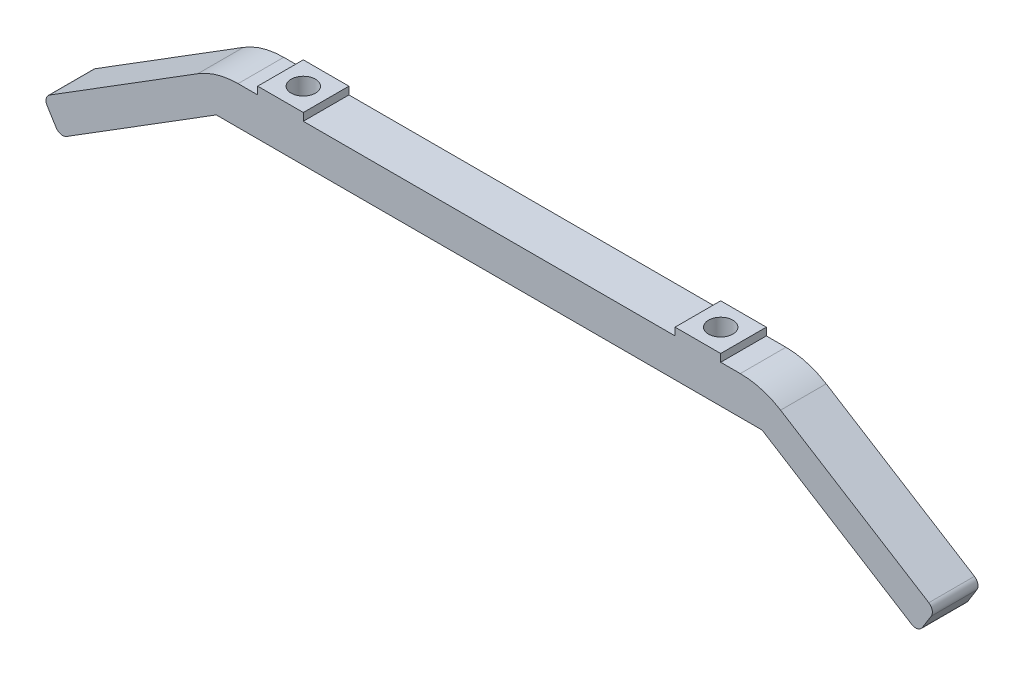
from build123d import *

# Parameters (mm, degrees)
EXTRUDE_1_DEPTH      = 3
SKETCH_7_R           = 2.25
CUT_EXTRUDE_2_DEPTH  = 4.0000001
SKETCH_8_R           = 8
CUT_EXTRUDE_3_DEPTH  = 4.0000001
CUT_EXTRUDE_4_DEPTH  = 3
CUT_EXTRUDE_5_DEPTH  = 3
CUT_EXTRUDE_8_DEPTH  = 3
SKETCH_12_R          = 1.7
CUT_EXTRUDE_9_DEPTH  = 3
SKETCH_13_R          = 1.7
CUT_EXTRUDE_11_DEPTH = 3
CUT_EXTRUDE_12_DEPTH = 4.0000001
FILLET_1_R           = 2
FILLET_2_R           = 2
CUT_EXTRUDE_13_DEPTH = 4.0000001
CUT_EXTRUDE_14_DEPTH = 4.0000001
CUT_EXTRUDE_15_DEPTH = 4.0000001
CUT_EXTRUDE_16_DEPTH = 4.0000001
SKETCH_19_W          = 174.604309186
SKETCH_19_H          = 153.794857067
CUT_EXTRUDE_17_DEPTH = 10
SKETCH_20_R          = 1.7
SKETCH_20_R_2        = 2.929115441
EXTRUDE_2_DEPTH      = 5
SKETCH_21_W          = 71.778327268
SKETCH_21_H          = 4.999657954
EXTRUDE_3_DEPTH      = 5
EXTRUDE_4_DEPTH      = 5
FILLET_3_R           = 10
SKETCH_23_W          = 71.778327268
SKETCH_23_H          = 4.999657954
EXTRUDE_5_DEPTH      = 5
FILLET_4_R           = 1
SKETCH_24_W          = 6
SKETCH_24_H          = 4.999657954
EXTRUDE_7_DEPTH      = 55
EXTRUDE_8_DEPTH      = 4.999658
FILLET_5_R           = 8
FILLET_6_R           = 12
SKETCH_27_W          = 5
SKETCH_27_H          = 6
EXTRUDE_9_DEPTH      = 4.999658
FILLET_7_R           = 1
FILLET_8_R           = 1
FILLET_9_R           = 1
SKETCH_28_R          = 1.6
CUT_EXTRUDE_19_DEPTH = 50
EXTRUDE_10_DEPTH     = 6
SKETCH_33_R          = 1.6
CUT_EXTRUDE_21_DEPTH = 10.999657954
SKETCH_34_W          = 162.843072653
SKETCH_34_H          = 93.113374014
CUT_EXTRUDE_22_DEPTH = 10
SKETCH_35_W          = 6
SKETCH_35_H          = 6
SKETCH_35_R          = 1.6
EXTRUDE_11_DEPTH     = 1
CUT_EXTRUDE_23_DEPTH = 90
SKETCH_37_W          = 26
SKETCH_37_H          = 5
CUT_EXTRUDE_24_DEPTH = 90
FILLET_10_R          = 10
FILLET_11_R          = 1


with BuildPart() as part:
    # 草图1 → 凸台-拉伸1 (new body)
    with BuildSketch(Plane.XY):
        with BuildLine():
            Line((60, 106.603296002), (35.889163634, 121.664519159))
            Line((35.889163634, 121.664519159), (-35.889163634, 121.664519159))
            Line((-35.889163634, 121.664519159), (-60, 106.603296002))
            Line((-60, 106.603296002), (-60, 94.801892265))
            Line((-60, 94.801892265), (-45, 94.801892265))
            ThreePointArc((-45, 94.801892265), (-43.762563133, 94.289329132), (-43.25, 93.051892265))
            Line((-43.25, 93.051892265), (-37.75, 93.051892265))
            ThreePointArc((-37.75, 93.051892265), (-37.237436867, 94.289329132), (-36, 94.801892265))
            Line((-36, 94.801892265), (-21, 94.801892265))
            ThreePointArc((-21, 94.801892265), (-19.762563133, 94.289329132), (-19.25, 93.051892265))
            Line((-19.25, 93.051892265), (19.25, 93.051892265))
            ThreePointArc((19.25, 93.051892265), (19.762563133, 94.289329132), (21, 94.801892265))
            Line((21, 94.801892265), (36, 94.801892265))
            ThreePointArc((36, 94.801892265), (37.237436867, 94.289329132), (37.75, 93.051892265))
            Line((37.75, 93.051892265), (43.25, 93.051892265))
            ThreePointArc((43.25, 93.051892265), (43.762563133, 94.289329132), (45, 94.801892265))
            Line((45, 94.801892265), (60, 94.801892265))
            Line((60, 94.801892265), (60, 106.603296002))
        make_face()
        with BuildLine():
            Line((66.901694095, 102.292041372), (60, 106.603296002))
            Line((60, 106.603296002), (60, 94.801892265))
            ThreePointArc((60, 94.801892265), (61.237436867, 94.289329132), (61.75, 93.051892265))
            Line((61.75, 93.051892265), (66.901694095, 93.051892265))
            Line((66.901694095, 93.051892265), (66.901694095, 102.292041372))
        make_face()
        with BuildLine():
            Line((-60, 94.801892265), (-60, 106.603296002))
            Line((-60, 106.603296002), (-66.901694095, 102.292041372))
            Line((-66.901694095, 102.292041372), (-66.901694095, 93.051892265))
            Line((-66.901694095, 93.051892265), (-61.75, 93.051892265))
            ThreePointArc((-61.75, 93.051892265), (-61.237436867, 94.289329132), (-60, 94.801892265))
        make_face()
        with BuildLine():
            Line((66.901694095, 63.051892265), (66.901694095, 93.051892265))
            Line((66.901694095, 93.051892265), (61.75, 93.051892265))
            ThreePointArc((61.75, 93.051892265), (61.237436867, 91.814455398), (60, 91.301892265))
            Line((60, 91.301892265), (60, 64.801892265))
            ThreePointArc((60, 64.801892265), (61.237436867, 64.289329132), (61.75, 63.051892265))
            Line((61.75, 63.051892265), (66.901694095, 63.051892265))
        make_face()
        with BuildLine():
            Line((-61.75, 93.051892265), (-66.901694095, 93.051892265))
            Line((-66.901694095, 93.051892265), (-66.901694095, 63.051892265))
            Line((-66.901694095, 63.051892265), (-61.75, 63.051892265))
            ThreePointArc((-61.75, 63.051892265), (-61.237436867, 64.289329132), (-60, 64.801892265))
            Line((-60, 64.801892265), (-60, 91.301892265))
            ThreePointArc((-60, 91.301892265), (-61.237436867, 91.814455398), (-61.75, 93.051892265))
        make_face()
        with BuildLine():
            Line((66.901694095, 52.870133869), (66.901694095, 63.051892265))
            Line((66.901694095, 63.051892265), (61.75, 63.051892265))
            ThreePointArc((61.75, 63.051892265), (61.237436867, 61.814455398), (60, 61.301892265))
            Line((60, 61.301892265), (60, 31.261343001))
            Line((60, 31.261343001), (75, 31.261343001))
            Line((75, 31.261343001), (75, 40.933889795))
            ThreePointArc((75, 40.933889795), (69.117351927, 45.658052319), (66.901694095, 52.870133869))
        make_face()
        with BuildLine():
            Line((60, 64.801892265), (60, 91.301892265))
            Line((60, 91.301892265), (45, 91.301892265))
            ThreePointArc((45, 91.301892265), (43.762563133, 91.814455398), (43.25, 93.051892265))
            Line((43.25, 93.051892265), (37.75, 93.051892265))
            ThreePointArc((37.75, 93.051892265), (37.237436867, 91.814455398), (36, 91.301892265))
            Line((36, 91.301892265), (21, 91.301892265))
            ThreePointArc((21, 91.301892265), (19.762563133, 91.814455398), (19.25, 93.051892265))
            Line((19.25, 93.051892265), (-19.25, 93.051892265))
            ThreePointArc((-19.25, 93.051892265), (-19.762563133, 91.814455398), (-21, 91.301892265))
            Line((-21, 91.301892265), (-36, 91.301892265))
            ThreePointArc((-36, 91.301892265), (-37.237436867, 91.814455398), (-37.75, 93.051892265))
            Line((-37.75, 93.051892265), (-43.25, 93.051892265))
            ThreePointArc((-43.25, 93.051892265), (-43.762563133, 91.814455398), (-45, 91.301892265))
            Line((-45, 91.301892265), (-60, 91.301892265))
            Line((-60, 91.301892265), (-60, 64.801892265))
            Line((-60, 64.801892265), (-45, 64.801892265))
            ThreePointArc((-45, 64.801892265), (-43.762563133, 64.289329132), (-43.25, 63.051892265))
            Line((-43.25, 63.051892265), (-37.75, 63.051892265))
            ThreePointArc((-37.75, 63.051892265), (-37.237436867, 64.289329132), (-36, 64.801892265))
            Line((-36, 64.801892265), (-21, 64.801892265))
            ThreePointArc((-21, 64.801892265), (-19.762563133, 64.289329132), (-19.25, 63.051892265))
            Line((-19.25, 63.051892265), (19.25, 63.051892265))
            ThreePointArc((19.25, 63.051892265), (19.762563133, 64.289329132), (21, 64.801892265))
            Line((21, 64.801892265), (36, 64.801892265))
            ThreePointArc((36, 64.801892265), (37.237436867, 64.289329132), (37.75, 63.051892265))
            Line((37.75, 63.051892265), (43.25, 63.051892265))
            ThreePointArc((43.25, 63.051892265), (43.762563133, 64.289329132), (45, 64.801892265))
            Line((45, 64.801892265), (60, 64.801892265))
        make_face()
        with BuildLine():
            Line((-61.75, 63.051892265), (-66.901694095, 63.051892265))
            Line((-66.901694095, 63.051892265), (-66.901694095, 52.870133869))
            ThreePointArc((-66.901694095, 52.870133869), (-69.117351927, 45.658052319), (-75, 40.933889795))
            Line((-75, 40.933889795), (-75, 31.261343001))
            Line((-75, 31.261343001), (-60, 31.261343001))
            Line((-60, 31.261343001), (-60, 61.301892265))
            ThreePointArc((-60, 61.301892265), (-61.237436867, 61.814455398), (-61.75, 63.051892265))
        make_face()
        with BuildLine():
            Line((60, 31.261343001), (60, 61.301892265))
            Line((60, 61.301892265), (45, 61.301892265))
            ThreePointArc((45, 61.301892265), (43.762563133, 61.814455398), (43.25, 63.051892265))
            Line((43.25, 63.051892265), (37.75, 63.051892265))
            ThreePointArc((37.75, 63.051892265), (37.237436867, 61.814455398), (36, 61.301892265))
            Line((36, 61.301892265), (21, 61.301892265))
            ThreePointArc((21, 61.301892265), (19.762563133, 61.814455398), (19.25, 63.051892265))
            Line((19.25, 63.051892265), (-19.25, 63.051892265))
            ThreePointArc((-19.25, 63.051892265), (-19.762563133, 61.814455398), (-21, 61.301892265))
            Line((-21, 61.301892265), (-36, 61.301892265))
            ThreePointArc((-36, 61.301892265), (-37.237436867, 61.814455398), (-37.75, 63.051892265))
            Line((-37.75, 63.051892265), (-43.25, 63.051892265))
            ThreePointArc((-43.25, 63.051892265), (-43.762563133, 61.814455398), (-45, 61.301892265))
            Line((-45, 61.301892265), (-60, 61.301892265))
            Line((-60, 61.301892265), (-60, 31.261343001))
            Line((-60, 31.261343001), (60, 31.261343001))
        make_face()
        with BuildLine():
            Line((60, -58.312864289), (60, 23.940028391))
            Line((60, 23.940028391), (-60, 23.940028391))
            Line((-60, 23.940028391), (-60, -58.312864289))
            Line((-60, -58.312864289), (-45, -58.312864289))
            ThreePointArc((-45, -58.312864289), (-43.25, -60.062864289), (-45, -61.812864289))
            Line((-45, -61.812864289), (-60, -61.812864289))
            Line((-60, -61.812864289), (-60, -88.312864289))
            Line((-60, -88.312864289), (-45, -88.312864289))
            ThreePointArc((-45, -88.312864289), (-43.25, -90.062864289), (-45, -91.812864289))
            Line((-45, -91.812864289), (-60, -91.812864289))
            Line((-60, -91.812864289), (-60, -111.849967256))
            Line((-60, -111.849967256), (-38.845469114, -105.590576733))
            ThreePointArc((-38.845469114, -105.590576733), (-36.037784492, -104.975210108), (-33.17088573, -104.768665882))
            Line((-33.17088573, -104.768665882), (33.17088573, -104.768665882))
            ThreePointArc((33.17088573, -104.768665882), (36.037784492, -104.975210108), (38.845469114, -105.590576733))
            Line((38.845469114, -105.590576733), (60, -111.849967256))
            Line((60, -111.849967256), (60, -91.812864289))
            Line((60, -91.812864289), (45, -91.812864289))
            ThreePointArc((45, -91.812864289), (43.762563133, -91.300301156), (43.25, -90.062864289))
            ThreePointArc((43.25, -90.062864289), (43.762563133, -88.825427422), (45, -88.312864289))
            Line((45, -88.312864289), (60, -88.312864289))
            Line((60, -88.312864289), (60, -61.812864289))
            Line((60, -61.812864289), (45, -61.812864289))
            ThreePointArc((45, -61.812864289), (43.762563133, -61.300301156), (43.25, -60.062864289))
            ThreePointArc((43.25, -60.062864289), (43.762563133, -58.825427422), (45, -58.312864289))
            Line((45, -58.312864289), (60, -58.312864289))
        make_face()
        with BuildLine():
            ThreePointArc((-21, -88.312864289), (-19.762563133, -88.825427422), (-19.25, -90.062864289))
            ThreePointArc((-19.25, -90.062864289), (-19.762563133, -91.300301156), (-21, -91.812864289))
            Line((-21, -91.812864289), (-36, -91.812864289))
            ThreePointArc((-36, -91.812864289), (-37.75, -90.062864289), (-36, -88.312864289))
            Line((-36, -88.312864289), (-21, -88.312864289))
        make_face(mode=Mode.SUBTRACT)
        with BuildLine():
            ThreePointArc((-21, -58.312864289), (-19.762563133, -58.825427422), (-19.25, -60.062864289))
            ThreePointArc((-19.25, -60.062864289), (-19.762563133, -61.300301156), (-21, -61.812864289))
            Line((-21, -61.812864289), (-36, -61.812864289))
            ThreePointArc((-36, -61.812864289), (-37.75, -60.062864289), (-36, -58.312864289))
            Line((-36, -58.312864289), (-21, -58.312864289))
        make_face(mode=Mode.SUBTRACT)
        with BuildLine():
            ThreePointArc((36, -88.312864289), (37.237436867, -88.825427422), (37.75, -90.062864289))
            ThreePointArc((37.75, -90.062864289), (37.237436867, -91.300301156), (36, -91.812864289))
            Line((36, -91.812864289), (21, -91.812864289))
            ThreePointArc((21, -91.812864289), (19.762563133, -91.300301156), (19.25, -90.062864289))
            ThreePointArc((19.25, -90.062864289), (19.762563133, -88.825427422), (21, -88.312864289))
            Line((21, -88.312864289), (36, -88.312864289))
        make_face(mode=Mode.SUBTRACT)
        with BuildLine():
            ThreePointArc((36, -58.312864289), (37.237436867, -58.825427422), (37.75, -60.062864289))
            ThreePointArc((37.75, -60.062864289), (37.237436867, -61.300301156), (36, -61.812864289))
            Line((36, -61.812864289), (21, -61.812864289))
            ThreePointArc((21, -61.812864289), (19.762563133, -61.300301156), (19.25, -60.062864289))
            ThreePointArc((19.25, -60.062864289), (19.762563133, -58.825427422), (21, -58.312864289))
            Line((21, -58.312864289), (36, -58.312864289))
        make_face(mode=Mode.SUBTRACT)
        with BuildLine():
            Line((75, 23.940028391), (60, 23.940028391))
            Line((60, 23.940028391), (60, -58.312864289))
            ThreePointArc((60, -58.312864289), (61.237436867, -58.825427422), (61.75, -60.062864289))
            Line((61.75, -60.062864289), (67.402721334, -60.062864289))
            add(Edge.make_bspline(
                [(75, 10.562559835), (72.695878257, 1.907314233), (70.339582535, -13.372796253), (67.818206704, -36.939032951), (67.208860388, -51.77269444), (67.402721334, -60.062864289)],
                knots=[0, 0, 0, 0, 0.235246678, 0.40629419, 0.624108181, 0.624108181, 0.624108181, 0.624108181], degree=3))
            Line((75, 10.562559835), (75, 23.940028391))
        make_face()
        with BuildLine():
            Line((-60, -58.312864289), (-60, 23.940028391))
            Line((-60, 23.940028391), (-75, 23.940028391))
            Line((-75, 23.940028391), (-75, 10.562559835))
            add(Edge.make_bspline(
                [(-75, 10.562559835), (-72.695878257, 1.907314233), (-70.339582535, -13.372796253), (-67.818206704, -36.939032951), (-67.208860388, -51.77269444), (-67.402721334, -60.062864289)],
                knots=[0, 0, 0, 0, 0.235246678, 0.40629419, 0.624108181, 0.624108181, 0.624108181, 0.624108181], degree=3))
            add(Edge.make_bspline(
                [(-67.402721334, -60.062864289), (-67.560325872, -66.802583754), (-68.323504015, -76.843670093), (-70.154131955, -86.778530076), (-70.533712858, -90.062864289)],
                knots=[0.624108181, 0.624108181, 0.624108181, 0.624108181, 0.801186001, 0.888408652, 0.888408652, 0.888408652, 0.888408652], degree=3))
            add(Edge.make_bspline(
                [(-70.533712858, -90.062864289), (-71.019342956, -94.264792095), (-71.137422935, -98.476048206), (-70.1742624, -102.732794059)],
                knots=[0.888408652, 0.888408652, 0.888408652, 0.888408652, 1, 1, 1, 1], degree=3))
            Line((-70.1742624, -102.732794059), (-66.460817635, -113.761651372))
            Line((-66.460817635, -113.761651372), (-60, -111.849967256))
            Line((-60, -111.849967256), (-60, -91.812864289))
            ThreePointArc((-60, -91.812864289), (-61.75, -90.062864289), (-60, -88.312864289))
            Line((-60, -88.312864289), (-60, -61.812864289))
            ThreePointArc((-60, -61.812864289), (-61.75, -60.062864289), (-60, -58.312864289))
        make_face()
        with BuildLine():
            Line((67.402721334, -60.062864289), (61.75, -60.062864289))
            ThreePointArc((61.75, -60.062864289), (61.237436867, -61.300301156), (60, -61.812864289))
            Line((60, -61.812864289), (60, -88.312864289))
            ThreePointArc((60, -88.312864289), (61.237436867, -88.825427422), (61.75, -90.062864289))
            Line((61.75, -90.062864289), (70.533712858, -90.062864289))
            add(Edge.make_bspline(
                [(67.402721334, -60.062864289), (67.560325872, -66.802583754), (68.323504015, -76.843670093), (70.154131955, -86.778530076), (70.533712858, -90.062864289)],
                knots=[0.624108181, 0.624108181, 0.624108181, 0.624108181, 0.801186001, 0.888408652, 0.888408652, 0.888408652, 0.888408652], degree=3))
        make_face()
        with BuildLine():
            add(Edge.make_bspline(
                [(70.533712858, -90.062864289), (71.019342956, -94.264792095), (71.137422935, -98.476048206), (70.1742624, -102.732794059)],
                knots=[0.888408652, 0.888408652, 0.888408652, 0.888408652, 1, 1, 1, 1], degree=3))
            Line((70.533712858, -90.062864289), (61.75, -90.062864289))
            ThreePointArc((61.75, -90.062864289), (61.237436867, -91.300301156), (60, -91.812864289))
            Line((60, -91.812864289), (60, -111.849967256))
            Line((60, -111.849967256), (66.460817635, -113.761651372))
            Line((66.460817635, -113.761651372), (70.1742624, -102.732794059))
        make_face()
    extrude(amount=EXTRUDE_1_DEPTH)

    # 草图7 → 切除-拉伸2 (cut, through all)
    with BuildSketch(Plane(origin=(0, 0, 0), x_dir=(-1, 0, 0), z_dir=(0, 0, -1))):
        with Locations((-21, 41.261343001)):
            Circle(SKETCH_7_R)
        with Locations((21, 41.261343001)):
            Circle(SKETCH_7_R)
        with Locations((-21, 13.940028391)):
            Circle(SKETCH_7_R)
        with Locations((21, 13.940028391)):
            Circle(SKETCH_7_R)
    extrude(amount=-CUT_EXTRUDE_2_DEPTH, mode=Mode.SUBTRACT)

    # 草图8 → 切除-拉伸3 (cut, through all)
    with BuildSketch(Plane.XY.offset(3)):
        with BuildLine():
            Line((-12.621438714, -0.378557945), (-33.409010345, 20.409013685))
            ThreePointArc((-33.409010345, 20.409013685), (-36.590999434, 20.409013643), (-36.590999309, 17.227024553))
            Line((-36.590999309, 17.227024553), (-15.803426586, -3.560545984))
            ThreePointArc((-15.803426586, -3.560545984), (-12.621438673, -3.560545859), (-12.621438714, -0.378557945))
        make_face()
        with BuildLine():
            Line((33.410462056, 20.410458798), (12.572988319, -0.427010824))
            ThreePointArc((12.572988319, -0.427010824), (12.644570441, -3.584764993), (15.803045702, -3.56090242))
            Line((15.803045702, -3.56090242), (34.999999982, 15.636052774))
            Line((34.999999982, 15.636052774), (36.588086952, 17.224139819))
            ThreePointArc((36.588086952, 17.224139819), (36.592433993, 20.406111757), (33.410462056, 20.410458798))
        make_face()
        with BuildLine():
            Line((-15.803784812, -28.80377835), (-36.591002186, -49.590991619))
            ThreePointArc((-36.591002186, -49.590991619), (-36.591002403, -52.772972232), (-33.40902179, -52.772972254))
            Line((-33.40902179, -52.772972254), (-12.573723916, -31.937673388))
            ThreePointArc((-12.573723916, -31.937673388), (-12.64530628, -28.779915954), (-15.803784812, -28.80377835))
        make_face()
        with BuildLine():
            Line((36.590992666, -49.590989326), (15.803414627, -28.803411286))
            ThreePointArc((15.803414627, -28.803411286), (12.654338964, -28.769774302), (12.55344336, -31.917412949))
            Line((12.55344336, -31.917412949), (33.409007381, -52.772974779))
            ThreePointArc((33.409007381, -52.772974779), (36.590992708, -52.772974653), (36.590992666, -49.590989326))
        make_face()
        with Locations((-0.000368782, -16.182341354)):
            Circle(SKETCH_8_R)
    extrude(amount=-CUT_EXTRUDE_3_DEPTH, mode=Mode.SUBTRACT)

    # 草图9 → 切除-拉伸4 (cut)
    with BuildSketch(Plane.XY.offset(3)):
        with BuildLine():
            Line((55, -100.49704609), (20, -100.49704609))
            ThreePointArc((20, -100.49704609), (18.25, -98.74704609), (20, -96.99704609))
            Line((20, -96.99704609), (55, -96.99704609))
            ThreePointArc((55, -96.99704609), (56.75, -98.74704609), (55, -100.49704609))
        make_face()
        with BuildLine():
            Line((-55, -96.99704609), (-20, -96.99704609))
            ThreePointArc((-20, -96.99704609), (-18.25, -98.74704609), (-20, -100.49704609))
            Line((-20, -100.49704609), (-55, -100.49704609))
            ThreePointArc((-55, -100.49704609), (-56.75, -98.74704609), (-55, -96.99704609))
        make_face()
    extrude(amount=-CUT_EXTRUDE_4_DEPTH, mode=Mode.SUBTRACT)

    # 草图10 → 切除-拉伸5 (cut)
    with BuildSketch(Plane.XY.offset(3)):
        with BuildLine():
            Line((12.5, -80.062864289), (-12.5, -80.062864289))
            ThreePointArc((-12.5, -80.062864289), (-17.5, -75.062864289), (-12.5, -70.062864289))
            Line((-12.5, -70.062864289), (12.5, -70.062864289))
            ThreePointArc((12.5, -70.062864289), (17.5, -75.062864289), (12.5, -80.062864289))
        make_face()
    extrude(amount=-CUT_EXTRUDE_5_DEPTH, mode=Mode.SUBTRACT)

    # 草图11 → 切除-拉伸8 (cut)
    with BuildSketch(Plane.XY.offset(3)):
        with BuildLine():
            Line((15, 73.051892265), (-15, 73.051892265))
            ThreePointArc((-15, 73.051892265), (-20, 78.051892265), (-15, 83.051892265))
            Line((-15, 83.051892265), (15, 83.051892265))
            ThreePointArc((15, 83.051892265), (20, 78.051892265), (15, 73.051892265))
        make_face()
    extrude(amount=-CUT_EXTRUDE_8_DEPTH, mode=Mode.SUBTRACT)

    # 草图12 → 切除-拉伸9 (cut)
    with BuildSketch(Plane.XY.offset(3)):
        with Locations((0, 114.371786435)):
            Circle(SKETCH_12_R)
        with Locations((0, 98.371786435)):
            Circle(SKETCH_12_R)
        with Locations((8, 106.371786435)):
            Circle(SKETCH_12_R)
        with Locations((-8, 106.371786435)):
            Circle(SKETCH_12_R)
    extrude(amount=-CUT_EXTRUDE_9_DEPTH, mode=Mode.SUBTRACT)

    # 草图13 → 切除-拉伸11 (cut)
    with BuildSketch(Plane.XY.offset(3)):
        with Locations((0, -84.415765086)):
            Circle(SKETCH_13_R)
        with Locations((8, -92.415765086)):
            Circle(SKETCH_13_R)
        with Locations((0, -100.415765086)):
            Circle(SKETCH_13_R)
        with Locations((-8, -92.415765086)):
            Circle(SKETCH_13_R)
    extrude(amount=-CUT_EXTRUDE_11_DEPTH, mode=Mode.SUBTRACT)

    # 草图14 → 切除-拉伸12 (cut, through all)
    with BuildSketch(Plane.XY.offset(3)):
        with BuildLine():
            Line((-55.475501567, 8.919687236), (-55.475501567, -46.080312764))
            ThreePointArc((-55.475501567, -46.080312764), (-57.225501567, -47.830312764), (-58.975501567, -46.080312764))
            Line((-58.975501567, -46.080312764), (-58.975501567, 8.919687236))
            ThreePointArc((-58.975501567, 8.919687236), (-57.225501567, 10.669687236), (-55.475501567, 8.919687236))
        make_face()
        with BuildLine():
            Line((58.975501567, 8.919687236), (58.975501567, -46.080312764))
            ThreePointArc((58.975501567, -46.080312764), (57.225501567, -47.830312764), (55.475501567, -46.080312764))
            Line((55.475501567, -46.080312764), (55.475501567, 8.919687236))
            ThreePointArc((55.475501567, 8.919687236), (57.225501567, 10.669687236), (58.975501567, 8.919687236))
        make_face()
    extrude(amount=-CUT_EXTRUDE_12_DEPTH, mode=Mode.SUBTRACT)

    # 圆角1
    fillet_1_edges = [part.edges().sort_by_distance(p)[0] for p in [
        (75, 31.261343001, 1.5),
        (-75, 31.261343001, 1.5),
    ]]
    fillet(fillet_1_edges, radius=FILLET_1_R)

    # 圆角2
    fillet_2_edges = [part.edges().sort_by_distance(p)[0] for p in [
        (-75, 23.940028391, 1.5),
        (75, 23.940028391, 1.5),
    ]]
    fillet(fillet_2_edges, radius=FILLET_2_R)

    # 草图15 → 切除-拉伸13 (cut, through all)
    with BuildSketch(Plane(origin=(0, 0, 0), x_dir=(-1, 0, 0), z_dir=(0, 0, -1))):
        with BuildLine():
            Line((-61.184216401, 102.403501276), (-34.774762862, 118.900592756))
            ThreePointArc((-34.774762862, 118.900592756), (-32.70788159, 118.423097411), (-33.185376934, 116.356216138))
            Line((-33.185376934, 116.356216138), (-59.594830473, 99.859124658))
            ThreePointArc((-59.594830473, 99.859124658), (-61.661711746, 100.336620003), (-61.184216401, 102.403501276))
        make_face()
        with BuildLine():
            Line((59.594830473, 99.859124658), (33.185376934, 116.356216138))
            ThreePointArc((33.185376934, 116.356216138), (32.70788159, 118.423097411), (34.774762862, 118.900592756))
            Line((34.774762862, 118.900592756), (61.184216401, 102.403501276))
            ThreePointArc((61.184216401, 102.403501276), (61.661711746, 100.336620003), (59.594830473, 99.859124658))
        make_face()
    extrude(amount=-CUT_EXTRUDE_13_DEPTH, mode=Mode.SUBTRACT)

    # 草图16 → 切除-拉伸14 (cut, through all)
    with BuildSketch(Plane(origin=(0, 0, 0), x_dir=(-1, 0, 0), z_dir=(0, 0, -1))):
        with BuildLine():
            Line((-61.516979467, 42.761343001), (-32.056291893, 42.761343001))
            ThreePointArc((-32.056291893, 42.761343001), (-30.556291893, 41.261343001), (-32.056291893, 39.761343001))
            Line((-32.056291893, 39.761343001), (-61.516979467, 39.761343001))
            ThreePointArc((-61.516979467, 39.761343001), (-63.016979467, 41.261343001), (-61.516979467, 42.761343001))
        make_face()
        with BuildLine():
            Line((61.516979467, 39.761343001), (32.056291893, 39.761343001))
            ThreePointArc((32.056291893, 39.761343001), (30.556291893, 41.261343001), (32.056291893, 42.761343001))
            Line((32.056291893, 42.761343001), (61.516979467, 42.761343001))
            ThreePointArc((61.516979467, 42.761343001), (63.016979467, 41.261343001), (61.516979467, 39.761343001))
        make_face()
    extrude(amount=-CUT_EXTRUDE_14_DEPTH, mode=Mode.SUBTRACT)

    # 草图17 → 切除-拉伸15 (cut, through all)
    with BuildSketch(Plane(origin=(0, 0, 0), x_dir=(-1, 0, 0), z_dir=(0, 0, -1))):
        Polygon((-28.645414283, -8.118433382), (-34.644957411, -20.11751964), (-34.644957411, -29.946558382), (-37.580904049, -29.946558382), (-37.580904049, -20.11751964), (-43.580447177, -8.118433382), (-40.64450054, -8.118433382), (-36.176755657, -17.43687271), (-36.049105803, -17.43687271), (-31.58136092, -8.118433382), align=None)
    extrude(amount=-CUT_EXTRUDE_15_DEPTH, mode=Mode.SUBTRACT)

    # 草图18 → 切除-拉伸16 (cut, through all)
    with BuildSketch(Plane(origin=(0, 0, 0), x_dir=(-1, 0, 0), z_dir=(0, 0, -1))):
        Polygon((46.06697123, -29.087529791), (43.131024593, -29.087529791), (43.131024593, -18.875541487), (35.854982926, -18.875541487), (35.854982926, -29.087529791), (32.919036289, -29.087529791), (32.919036289, -7.259404791), (35.854982926, -7.259404791), (35.854982926, -16.450194265), (43.131024593, -16.450194265), (43.131024593, -7.259404791), (46.06697123, -7.259404791), align=None)
    extrude(amount=-CUT_EXTRUDE_16_DEPTH, mode=Mode.SUBTRACT)

    # 草图19 → 切除-拉伸17 (cut)
    with BuildSketch(Plane(origin=(0, 0, 0), x_dir=(-1, 0, 0), z_dir=(0, 0, -1))):
        with Locations((0, -49.372787161)):
            Rectangle(SKETCH_19_W, SKETCH_19_H)
    extrude(amount=-CUT_EXTRUDE_17_DEPTH, mode=Mode.SUBTRACT)

    # 草图34 → 切除-拉伸22 (cut)
    with BuildSketch(Plane(origin=(0, 0, 0), x_dir=(-1, 0, 0), z_dir=(0, 0, -1))):
        with Locations((1.208964771, 75.898201893)):
            Rectangle(SKETCH_34_W, SKETCH_34_H)
    extrude(amount=-CUT_EXTRUDE_22_DEPTH, mode=Mode.SUBTRACT)


with BuildPart() as body_2:
    # 草图20 → 凸台-拉伸2 (new body)
    with BuildSketch(Plane.XY.offset(13)):
        with BuildLine():
            Line((-13, 106.371786435), (-13, 129.664519159))
            Line((-13, 129.664519159), (13, 129.664519159))
            Line((13, 129.664519159), (13, 106.371786435))
            ThreePointArc((13, 106.371786435), (0, 93.371786435), (-13, 106.371786435))
        make_face()
        with Locations((0, 98.371786435)):
            Circle(SKETCH_20_R, mode=Mode.SUBTRACT)
        with Locations((-8, 106.371786435)):
            Circle(SKETCH_20_R, mode=Mode.SUBTRACT)
        with Locations((8, 106.371786435)):
            Circle(SKETCH_20_R, mode=Mode.SUBTRACT)
        with Locations((0, 114.371786435)):
            Circle(SKETCH_20_R, mode=Mode.SUBTRACT)
        with Locations((0, 106.371786435)):
            Circle(SKETCH_20_R_2, mode=Mode.SUBTRACT)
    extrude(amount=EXTRUDE_2_DEPTH)

    # 草图21 → 凸台-拉伸3 (add)
    with BuildSketch(Plane.XY.offset(18)):
        with Locations((0, 127.164522428)):
            Rectangle(SKETCH_21_W, SKETCH_21_H)
    extrude(amount=-EXTRUDE_3_DEPTH)

    # 草图22 → 凸台-拉伸4 (add)
    with BuildSketch(Plane.XY.offset(18)):
        Polygon((-24.444581817, 124.664693451), (-13, 116.664693451), (-13, 124.664693451), align=None)
        Polygon((24.444581817, 124.664693451), (13, 116.664693451), (13, 124.664693451), align=None)
    extrude(amount=-EXTRUDE_4_DEPTH)

    # 圆角3
    fillet_3_edges = [body_2.edges().sort_by_distance(p)[0] for p in [
        (-24.444581817, 124.664693451, 15.5),
        (-13, 116.664693451, 15.5),
        (24.444581817, 124.664693451, 15.5),
        (13, 116.664693451, 15.5),
    ]]
    fillet(fillet_3_edges, radius=FILLET_3_R)

    # 草图23 → 凸台-拉伸5 (add)
    with BuildSketch(Plane(origin=(0, 0, 13), x_dir=(-1, 0, 0), z_dir=(0, 0, -1))):
        with Locations((0, 127.164522428)):
            Rectangle(SKETCH_23_W, SKETCH_23_H)
    extrude(amount=EXTRUDE_5_DEPTH)

    # 圆角4
    fillet_4_edges = [body_2.edges().sort_by_distance(p)[0] for p in [
        (0, 124.664693451, 13),
    ]]
    fillet(fillet_4_edges, radius=FILLET_4_R)

    # 草图24 → 凸台-拉伸7 (add)
    with BuildSketch(Plane(origin=(0, 0, 8), x_dir=(-1, 0, 0), z_dir=(0, 0, -1))):
        with Locations((-32.889163634, 127.164522428)):
            Rectangle(SKETCH_24_W, SKETCH_24_H)
        with Locations((32.889163634, 127.164522428)):
            Rectangle(SKETCH_24_W, SKETCH_24_H)
    extrude(amount=EXTRUDE_7_DEPTH)

    # 草图25 → 凸台-拉伸8 (add)
    with BuildSketch(Plane(origin=(0, 129.664351405, 0), x_dir=(1, 0, 0), z_dir=(0, 1, 0))):
        Polygon((-29.889163634, 2), (-13.889163634, -8), (-29.889163634, -8), align=None)
        Polygon((29.889163634, -8), (13.889163634, -8), (29.889163634, 2), align=None)
    extrude(amount=-EXTRUDE_8_DEPTH)

    # 圆角5
    fillet_5_edges = [body_2.edges().sort_by_distance(p)[0] for p in [
        (-13.889163634, 127.164522405, 8),
        (-29.889163634, 127.164522405, -2),
        (13.889163634, 127.164522405, 8),
        (29.889163634, 127.164522405, -2),
    ]]
    fillet(fillet_5_edges, radius=FILLET_5_R)

    # 圆角6
    fillet_6_edges = [body_2.edges().sort_by_distance(p)[0] for p in [
        (35.889163634, 127.164522428, 18),
        (-35.889163634, 127.164522428, 18),
    ]]
    fillet(fillet_6_edges, radius=FILLET_6_R)

    # 草图27 → 凸台-拉伸9 (add)
    with BuildSketch(Plane(origin=(0, 129.664351405, 0), x_dir=(1, 0, 0), z_dir=(0, 1, 0))):
        with Locations((-27.389163634, 9.433981132)):
            Rectangle(SKETCH_27_W, SKETCH_27_H)
        with Locations((-27.389163634, 24)):
            Rectangle(SKETCH_27_W, SKETCH_27_H)
        with Locations((27.389163634, 24)):
            Rectangle(SKETCH_27_W, SKETCH_27_H)
        with Locations((27.389163634, 9.433981132)):
            Rectangle(SKETCH_27_W, SKETCH_27_H)
        with Locations((-27.389163634, 44)):
            Rectangle(SKETCH_27_W, SKETCH_27_H)
        with Locations((27.389163634, 44)):
            Rectangle(SKETCH_27_W, SKETCH_27_H)
    extrude(amount=-EXTRUDE_9_DEPTH)

    # 圆角7
    fillet_7_edges = [body_2.edges().sort_by_distance(p)[0] for p in [
        (29.889163634, 127.164522428, -6.433981132),
        (-29.889163634, 127.164522428, -6.433981132),
        (-29.889163634, 127.164522405, -12.433981132),
        (-29.889163634, 127.164522405, -41),
        (29.889163634, 127.164522405, -41),
        (-29.889163634, 127.164522405, -27),
        (-29.889163634, 127.164522405, -21),
        (29.889163634, 127.164522405, -21),
        (29.889163634, 127.164522405, -27),
        (29.889163634, 127.164522405, -12.433981132),
    ]]
    fillet(fillet_7_edges, radius=FILLET_7_R)

    # 圆角8
    fillet_8_edges = [body_2.edges().sort_by_distance(p)[0] for p in [
        (-24.889163634, 127.164522405, -6.433981132),
        (-24.889163634, 127.164522405, -12.433981132),
        (-24.889163634, 127.164522405, -41),
        (24.889163634, 127.164522405, -41),
        (-24.889163634, 127.164522405, -21),
        (-24.889163634, 127.164522405, -27),
        (24.889163634, 127.164522405, -21),
        (24.889163634, 127.164522405, -27),
        (24.889163634, 127.164522405, -12.433981132),
        (24.889163634, 127.164522405, -6.433981132),
    ]]
    fillet(fillet_8_edges, radius=FILLET_8_R)

    # 圆角9
    fillet_9_edges = [body_2.edges().sort_by_distance(p)[0] for p in [
        (35.889163634, 127.164522428, -47),
        (-35.889163634, 127.164522428, -47),
        (-24.889163634, 127.164522405, -47),
        (24.889163634, 127.164522405, -47),
    ]]
    fillet(fillet_9_edges, radius=FILLET_9_R)

    # 草图28 → 切除-拉伸19 (cut)
    with BuildSketch(Plane(origin=(0, 129.664351405, 0), x_dir=(1, 0, 0), z_dir=(0, 1, 0))):
        with Locations((-27.445843009, 44)):
            Circle(SKETCH_28_R)
        with Locations((-27.445843009, 24)):
            Circle(SKETCH_28_R)
        with Locations((-27.445843009, 9.433981132)):
            Circle(SKETCH_28_R)
        with Locations((27.445843009, 9.433981132)):
            Circle(SKETCH_28_R)
        with Locations((27.445843009, 24)):
            Circle(SKETCH_28_R)
        with Locations((27.445843009, 44)):
            Circle(SKETCH_28_R)
    extrude(amount=-CUT_EXTRUDE_19_DEPTH, mode=Mode.SUBTRACT)

    # 草图32 → 凸台-拉伸10 (add)
    with BuildSketch(Plane.XY.offset(-6.433981132)):
        Polygon((-35.889163634, 129.664351405), (-56.41665643, 116.841521654), (-58.663321092, 120.438106306), (-35.889163634, 134.664351405), (35.889163634, 134.664351405), (58.663321092, 120.438106306), (56.41665643, 116.841521654), (35.889163634, 129.664351405), align=None)
    extrude(amount=-EXTRUDE_10_DEPTH)

    # 草图33 → 切除-拉伸21 (cut, through all)
    with BuildSketch(Plane.XZ.offset(-124.664693451)):
        with Locations((-27.445843009, -9.433981132)):
            Circle(SKETCH_33_R)
        with Locations((27.445843009, -9.433981132)):
            Circle(SKETCH_33_R)
    extrude(amount=-CUT_EXTRUDE_21_DEPTH, mode=Mode.SUBTRACT)

    # 草图35 → 凸台-拉伸11 (add)
    with BuildSketch(Plane(origin=(0, 134.664351405, 0), x_dir=(1, 0, 0), z_dir=(0, 1, 0))):
        with Locations((-27.445843009, 9.433981132)):
            Rectangle(SKETCH_35_W, SKETCH_35_H)
        with Locations((-27.445843009, 9.433981132)):
            Circle(SKETCH_35_R, mode=Mode.SUBTRACT)
        with Locations((27.445843009, 9.433981132)):
            Rectangle(SKETCH_35_W, SKETCH_35_H)
        with Locations((27.445843009, 9.433981132)):
            Circle(SKETCH_35_R, mode=Mode.SUBTRACT)
    extrude(amount=EXTRUDE_11_DEPTH)

    # 草图36 → 切除-拉伸23 (cut)
    with BuildSketch(Plane.XY.offset(18)):
        Polygon((-35.889163634, 129.664351405), (35.889163634, 129.664351405), (35.889163634, 124.664693451), (35.889163634, 87.058009176), (-35.889163634, 87.058009176), (-35.889163634, 124.664693451), align=None)
    extrude(amount=-CUT_EXTRUDE_23_DEPTH, mode=Mode.SUBTRACT)

    # 草图37 → 切除-拉伸24 (cut)
    with BuildSketch(Plane(origin=(0, 129.664519159, 0), x_dir=(1, 0, 0), z_dir=(0, 1, 0))):
        with Locations((0, -15.5)):
            Rectangle(SKETCH_37_W, SKETCH_37_H)
    extrude(amount=-CUT_EXTRUDE_24_DEPTH, mode=Mode.SUBTRACT)

    # 圆角10
    fillet_10_edges = [body_2.edges().sort_by_distance(p)[0] for p in [
        (35.889163634, 134.664351405, -9.433981132),
        (-35.889163634, 134.664351405, -9.433981132),
    ]]
    fillet(fillet_10_edges, radius=FILLET_10_R)

    # 圆角11
    fillet_11_edges = [body_2.edges().sort_by_distance(p)[0] for p in [
        (58.663321092, 120.438106306, -9.433981132),
        (-58.663321092, 120.438106306, -9.433981132),
        (-56.41665643, 116.841521654, -9.433981132),
        (56.41665643, 116.841521654, -9.433981132),
    ]]
    fillet(fillet_11_edges, radius=FILLET_11_R)


solid = body_2.part
